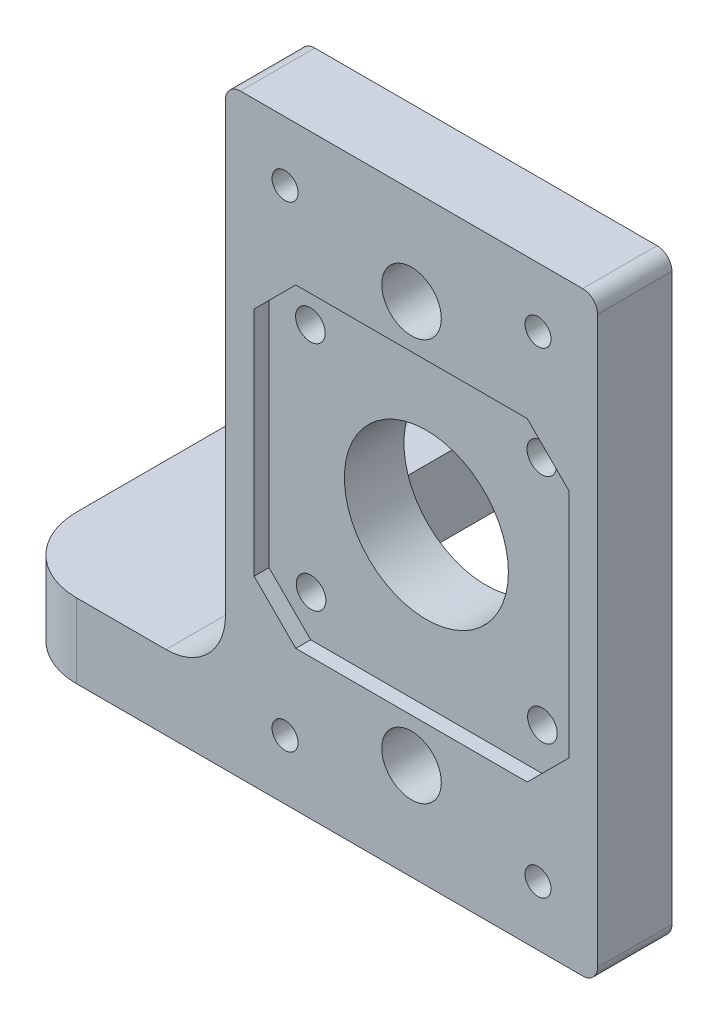
from build123d import *

# Parameters (mm, degrees)
ESBO_O1_W                     = 50
ESBO_O1_H                     = 80
RESSALTO_EXTRUS_O1_DEPTH      = 5
ESBO_O2_W                     = 42.3
ESBO_O2_H                     = 42.3
CORTE_EXTRUS_O1_DEPTH         = 2
ESBO_O3_R                     = 11.02
CORTE_EXTRUS_O2_DEPTH         = 24
ESBO_O4_R                     = 1.987893006
CORTE_EXTRUS_O3_DEPTH         = 24
PADR_OCIRCULAR1_COUNT         = 4
ESBO_O5_R                     = 4
CORTE_EXTRUS_O4_DEPTH         = 24
CHANFRO1_SIZE                 = 5.6
ESBO_O6_R                     = 1.75
CORTE_EXTRUS_O5_DEPTH         = 10
FILETE1_R                     = 2
ESBO_O7_W                     = 30
ESBO_O7_H                     = 10
RESSALTO_EXTRUS_O2_DEPTH      = 50
RESSALTO_EXTRUS_O2_DEPTH_BACK = 10
ESBO_O8_R                     = 4.05
CORTE_EXTRUS_O6_DEPTH         = 45
ESBO_O9_W                     = 12
ESBO_O9_H                     = 50
CORTE_EXTRUS_O7_DEPTH         = 45
FILETE2_R                     = 10
FILETE3_R                     = 8


with BuildPart() as part:
    # Esboço1 → Ressalto-extrusão1 (new body, symmetric)
    with BuildSketch(Plane.XY):
        Rectangle(ESBO_O1_W, ESBO_O1_H)
    extrude(amount=RESSALTO_EXTRUS_O1_DEPTH, both=True)

    # Esboço2 → Corte-extrusão1 (cut)
    with BuildSketch(Plane.XY.offset(5)):
        Rectangle(ESBO_O2_W, ESBO_O2_H)
    extrude(amount=-CORTE_EXTRUS_O1_DEPTH, mode=Mode.SUBTRACT)

    # Esboço3 → Corte-extrusão2 (cut)
    with BuildSketch(Plane.XY.offset(3)):
        Circle(ESBO_O3_R)
    extrude(amount=-CORTE_EXTRUS_O2_DEPTH, mode=Mode.SUBTRACT)

    # Esboço4 → Corte-extrusão3 (cut)
    with BuildSketch(Plane.XY.offset(3)):
        with Locations((-15.59, 15.5)):
            Circle(ESBO_O4_R)
    corte_extrus_o3 = extrude(amount=-CORTE_EXTRUS_O3_DEPTH, mode=Mode.SUBTRACT)

    # PadrãoCircular1: Corte-extrusão3 ×4 about axis
    padr_ocircular1_axis = Axis((0, 0, 0), (0, 0, 1))
    for i in range(1, PADR_OCIRCULAR1_COUNT):
        add(corte_extrus_o3.rotate(padr_ocircular1_axis, i * 360 / PADR_OCIRCULAR1_COUNT), mode=Mode.SUBTRACT)

    # Esboço5 → Corte-extrusão4 (cut)
    with BuildSketch(Plane.XY.offset(5)):
        with Locations((0, 27)):
            Circle(ESBO_O5_R)
        with Locations((0, -27)):
            Circle(ESBO_O5_R)
    extrude(amount=-CORTE_EXTRUS_O4_DEPTH, mode=Mode.SUBTRACT)

    # Chanfro1
    chanfro1_edges = [part.edges().sort_by_distance(p)[0] for p in [
        (21.15, 21.15, 4),
        (21.15, -21.15, 4),
        (-21.15, -21.15, 4),
        (-21.15, 21.15, 4),
    ]]
    chamfer(chanfro1_edges, length=CHANFRO1_SIZE)

    # Esboço6 → Corte-extrusão5 (cut)
    with BuildSketch(Plane(origin=(0, 0, -5), x_dir=(-1, 0, 0), z_dir=(0, 0, -1))):
        with Locations((-17, 32)):
            Circle(ESBO_O6_R)
        with Locations((17, 32)):
            Circle(ESBO_O6_R)
        with Locations((-17, -32)):
            Circle(ESBO_O6_R)
        with Locations((17, -32)):
            Circle(ESBO_O6_R)
    extrude(amount=-CORTE_EXTRUS_O5_DEPTH, mode=Mode.SUBTRACT)

    # Filete1
    filete1_edges = [part.edges().sort_by_distance(p)[0] for p in [
        (25, -40, 0),
        (-25, 40, 0),
        (25, 40, 0),
    ]]
    fillet(filete1_edges, radius=FILETE1_R)

    # Esboço7 → Ressalto-extrusão2 (add, two sides)
    with BuildSketch(Plane(origin=(0, 0, -5), x_dir=(-1, 0, 0), z_dir=(0, 0, -1))) as ressalto_extrus_o2_sk:
        with Locations((40, -35)):
            Rectangle(ESBO_O7_W, ESBO_O7_H)
    extrude(amount=RESSALTO_EXTRUS_O2_DEPTH)
    extrude(ressalto_extrus_o2_sk.sketch, amount=-RESSALTO_EXTRUS_O2_DEPTH_BACK)

    # Esboço8 → Corte-extrusão6 (cut)
    with BuildSketch(Plane(origin=(0, -40, 0), x_dir=(-1, 0, 0), z_dir=(0, -1, 0))):
        with Locations((46, 45.5)):
            Circle(ESBO_O8_R)
    extrude(amount=-CORTE_EXTRUS_O6_DEPTH, mode=Mode.SUBTRACT)

    # Esboço9 → Corte-extrusão7 (cut)
    with BuildSketch(Plane(origin=(0, -40, 0), x_dir=(-1, 0, 0), z_dir=(0, -1, 0))):
        with Locations((31, 30)):
            Rectangle(ESBO_O9_W, ESBO_O9_H)
    extrude(amount=-CORTE_EXTRUS_O7_DEPTH, mode=Mode.SUBTRACT)

    # Filete2
    filete2_edges = [part.edges().sort_by_distance(p)[0] for p in [
        (-55, -35, 5),
        (-37, -35, -5),
    ]]
    fillet(filete2_edges, radius=FILETE2_R)

    # Filete3
    filete3_edges = [part.edges().sort_by_distance(p)[0] for p in [
        (-25, -30, 0),
    ]]
    fillet(filete3_edges, radius=FILETE3_R)


solid = part.part
